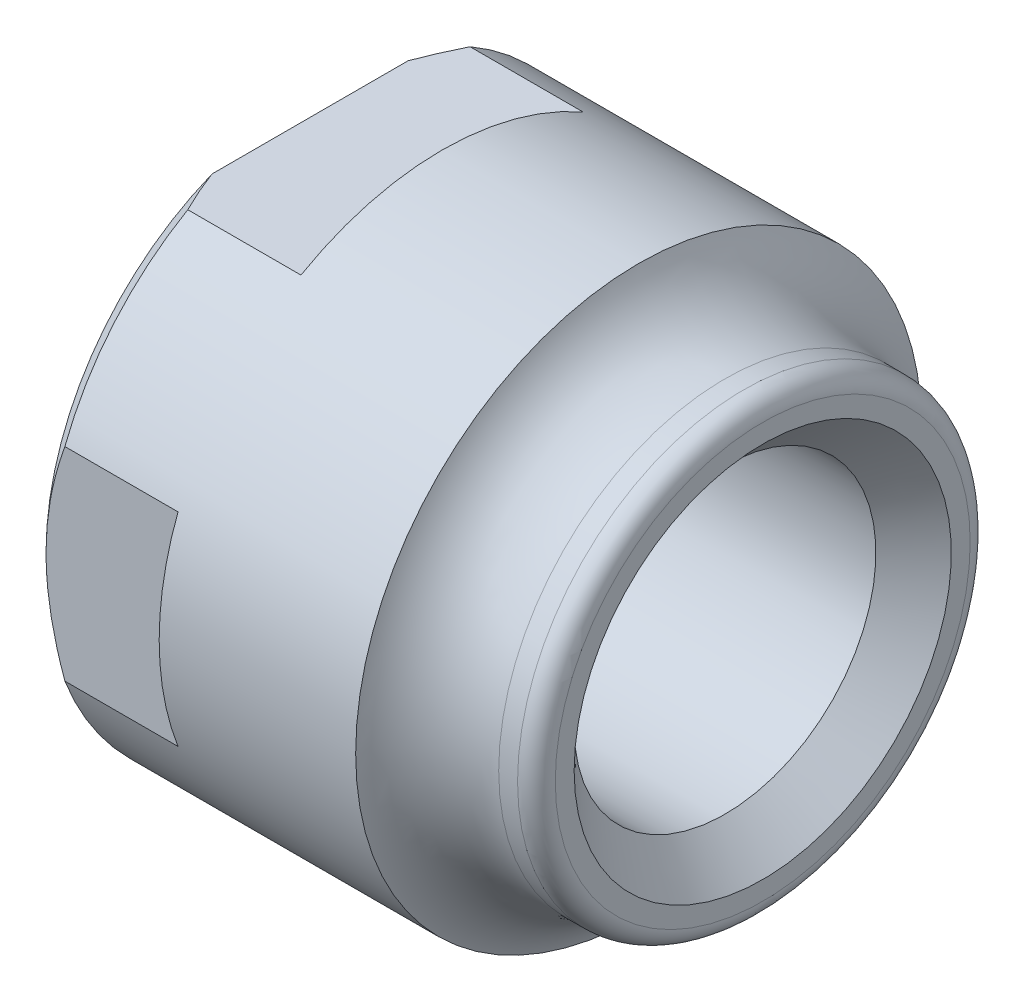
from build123d import *

# Parameters (mm, degrees)
CONG_1_R                = 0.5
CHANFREIN1_SIZE         = 1
CHANFREIN2_SIZE         = 0.5
ESQUISSE2_OUTSIDE_W     = 21.874
ESQUISSE2_OUTSIDE_H     = 21.874
ESQUISSE2_OUTSIDE_W_2   = 14
ESQUISSE2_OUTSIDE_H_2   = 13
ENL_V_MAT_EXTRU_1_DEPTH = 3.5


with BuildPart() as part:
    # Esquisse1 → Révolution1 (revolve)
    with BuildSketch(Plane.XY, mode=Mode.PRIVATE) as r_volution1_sk:
        with BuildLine():
            Line((0, 6), (1, 6))
            Line((1, 6), (1, 4))
            Line((1, 4), (-11, 4))
            Line((-11, 4), (-11, 7.5))
            Line((-11, 7.5), (-2.291287847, 7.5))
            ThreePointArc((-2.291287847, 7.5), (-1.369306394, 6.408349934), (0, 6))
        make_face()
    revolve(r_volution1_sk.sketch.rotate(Axis((-14.539906675, 0, 0), (1, 0, 0)), 90), axis=Axis((-14.539906675, 0, 0), (1, 0, 0)))  # turned: the seam where the file's is

    # Congé1
    cong_1_edges = [part.edges().sort_by_distance(p)[0] for p in [
        (1, 0, -6),
    ]]
    fillet(cong_1_edges, radius=CONG_1_R)

    # Chanfrein1
    chanfrein1_edges = [part.edges().sort_by_distance(p)[0] for p in [
        (1, 0, -4),
        (-11, 0, -4),
    ]]
    chamfer(chanfrein1_edges, length=CHANFREIN1_SIZE)

    # Chanfrein2
    chanfrein2_edges = [part.edges().sort_by_distance(p)[0] for p in [
        (-11, 0, -7.5),
    ]]
    chamfer(chanfrein2_edges, length=CHANFREIN2_SIZE)

    # Esquisse2 outside → Enlèv. mat.-Extru.1 (cut)
    with BuildSketch(Plane.ZY.offset(11)):
        Rectangle(ESQUISSE2_OUTSIDE_W, ESQUISSE2_OUTSIDE_H)
        Rectangle(ESQUISSE2_OUTSIDE_W_2, ESQUISSE2_OUTSIDE_H_2, mode=Mode.SUBTRACT)
    extrude(amount=-ENL_V_MAT_EXTRU_1_DEPTH, mode=Mode.SUBTRACT)


solid = part.part
